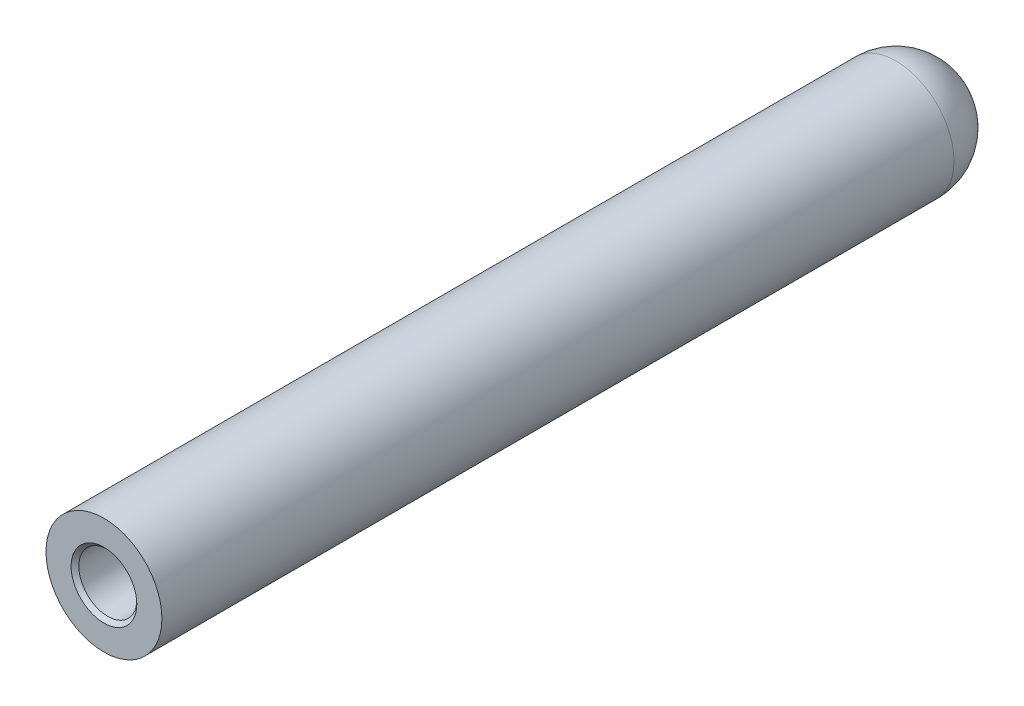
from build123d import *

# Parameters (mm, degrees)
SKETCH1_R           = 9.525
BOSS_EXTRUDE1_DEPTH = 139.7
FILLET1_R           = 9.525


with BuildPart() as part:
    # Sketch1 → Boss-Extrude1 (new body)
    with BuildSketch(Plane.XY):
        Circle(SKETCH1_R)
    extrude(amount=BOSS_EXTRUDE1_DEPTH)

    # Fillet1
    fillet1_edges = [part.edges().sort_by_distance(p)[0] for p in [
        (-9.525, 0, 0),
    ]]
    fillet(fillet1_edges, radius=FILLET1_R)

    # Sketch2 → 3/8-16 Tapped Hole1 (revolve, cut)
    with BuildSketch(Plane(origin=(0, 0, 139.7), x_dir=(0, -1, 0), z_dir=(1, 0, 0))):
        Polygon((0, 0), (0, 42.084865582), (3.96875, 39.7002), (3.96875, 31.75), (4.7625, 31.75), (4.7625, 0.635), (5.3975, 0), align=None)
    revolve(axis=Axis((0, 0, 146.05), (0, 0, -1)), mode=Mode.SUBTRACT)


solid = part.part
